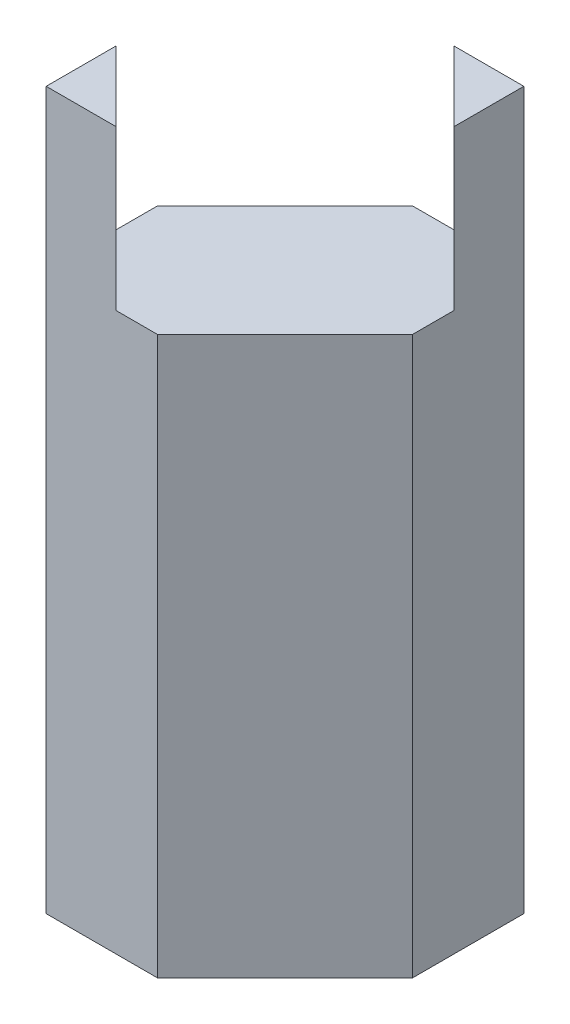
from build123d import *

# Parameters (mm, degrees)
SKETCH1_W           = 19.05
SKETCH1_H           = 19.05
BOSS_EXTRUDE1_DEPTH = 44.45
BOSS_EXTRUDE2_DEPTH = 12.7
CUT_EXTRUDE1_DEPTH  = 45.45


with BuildPart() as part:
    # Sketch1 → Boss-Extrude1 (new body)
    with BuildSketch(Plane(origin=(0, 0, 0), x_dir=(1, 0, 0), z_dir=(0, 1, 0))):
        Rectangle(SKETCH1_W, SKETCH1_H)
    extrude(amount=BOSS_EXTRUDE1_DEPTH)

    # Sketch2 → Boss-Extrude2 (add)
    with BuildSketch(Plane(origin=(0, 44.45, 0), x_dir=(1, 0, 0), z_dir=(0, 1, 0))):
        Polygon((-9.525, -9.525), (-3.957241205, -9.525), (-9.525, -3.957241205), align=None)
    boss_extrude2 = extrude(amount=BOSS_EXTRUDE2_DEPTH)

    # Mirror1: Boss-Extrude2 across plane
    add(boss_extrude2.mirror(Plane(origin=(0, 0, 0), x_dir=(0.707106781, 0, 0.707106781), z_dir=(-0.707106781, 0, 0.707106781))))

    # Sketch3 → Cut-Extrude1 (cut, through all)
    with BuildSketch(Plane(origin=(0, 44.45, 0), x_dir=(1, 0, 0), z_dir=(0, 1, 0))):
        Polygon((9.525, -9.525), (-0.635, -9.525), (9.525, 0.635), align=None)
    cut_extrude1 = extrude(amount=-CUT_EXTRUDE1_DEPTH, mode=Mode.SUBTRACT)

    # Mirror2: Cut-Extrude1 across plane
    add(cut_extrude1.mirror(Plane(origin=(0, 0, 0), x_dir=(-0.707106781, 0, 0.707106781), z_dir=(-0.707106781, 0, -0.707106781))), mode=Mode.SUBTRACT)


solid = part.part
